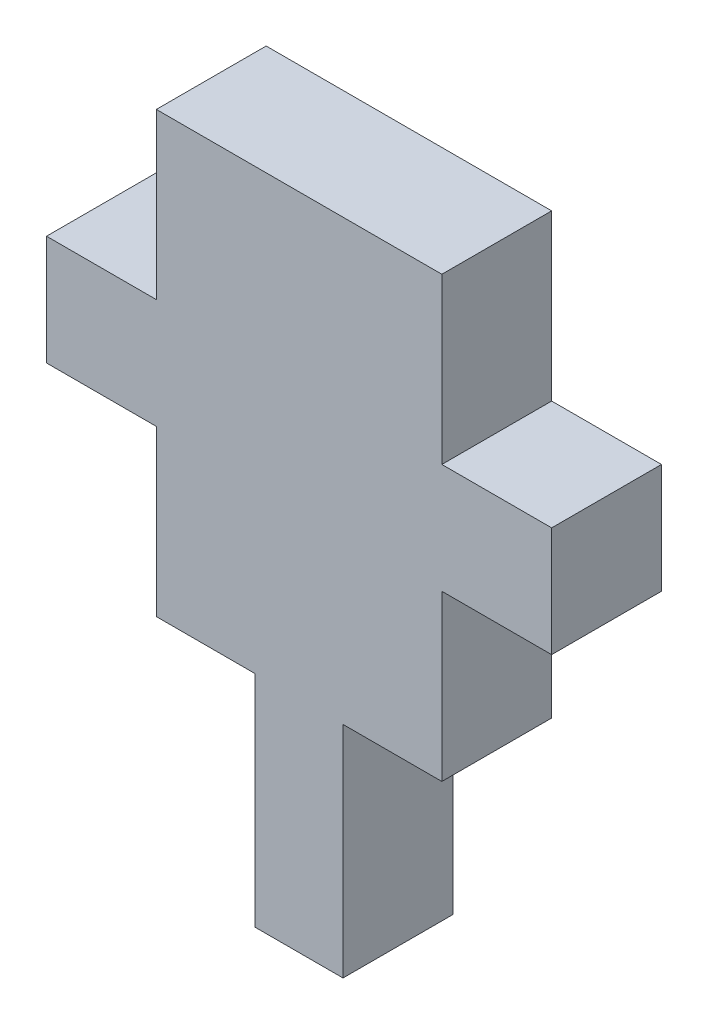
from build123d import *

# Parameters (mm, degrees)
ESQUISSE1_W        = 4
ESQUISSE1_H        = 10
ESQUISSE1_W_2      = 5
ESQUISSE1_H_2      = 5
ESQUISSE1_W_3      = 13
ESQUISSE1_H_3      = 20
BOSS_EXTRU_1_DEPTH = 5


with BuildPart() as part:
    # Esquisse1 → Boss.-Extru.1 (new body)
    with BuildSketch(Plane.XY):
        with Locations((6.5, -5)):
            Rectangle(ESQUISSE1_W, ESQUISSE1_H)
        with Locations((-2.5, 10)):
            Rectangle(ESQUISSE1_W_2, ESQUISSE1_H_2)
        with Locations((6.5, 10)):
            Rectangle(ESQUISSE1_W_3, ESQUISSE1_H_3)
        with Locations((15.5, 10)):
            Rectangle(ESQUISSE1_W_2, ESQUISSE1_H_2)
    extrude(amount=BOSS_EXTRU_1_DEPTH)


solid = part.part
